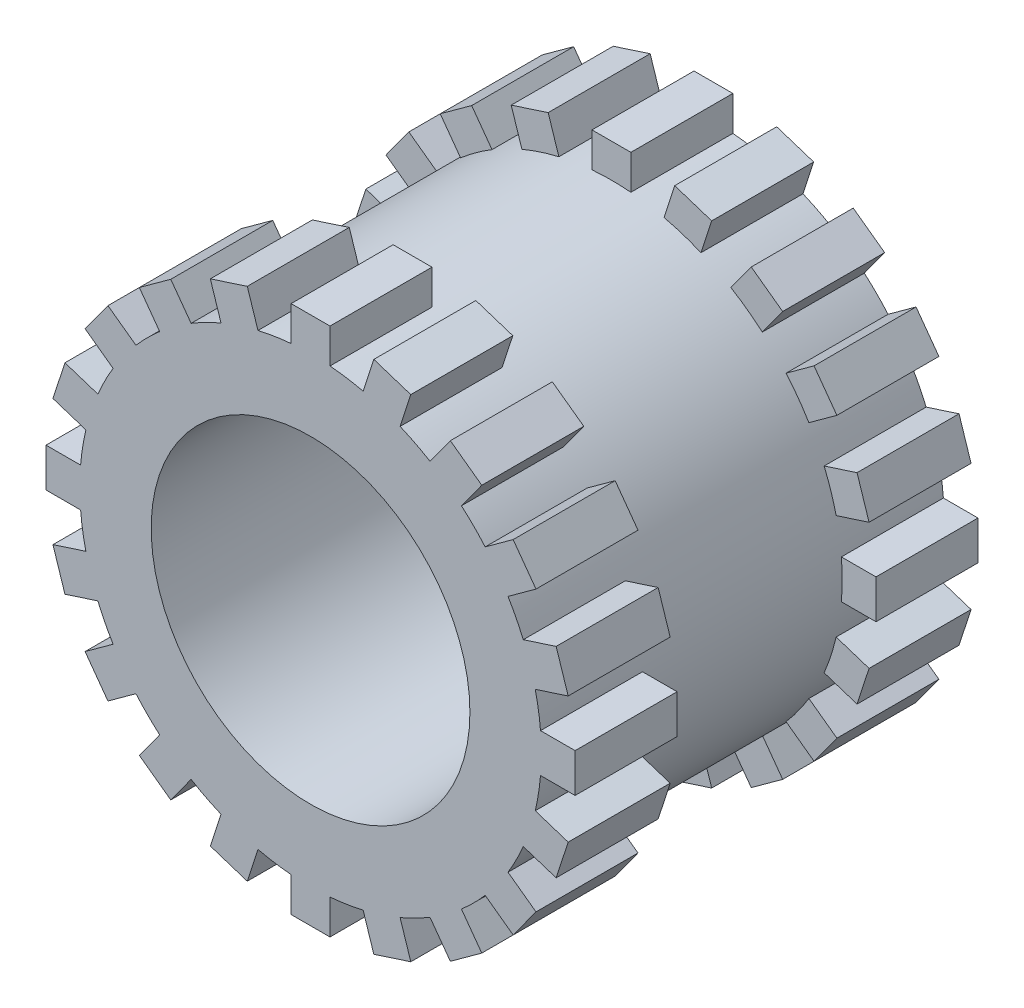
from build123d import *

# Parameters (mm, degrees)
SKETCH1_R                   = 1.81
BOSS_EXTRUDE1_DEPTH         = 1.58
TAP_DRILL_FOR_M3X0_5_TAP1_D = 2.5
SKETCH4_W                   = 0.3048
SKETCH4_H                   = 0.271427368
BOSS_EXTRUDE2_DEPTH         = 0.8
CIRPATTERN1_COUNT           = 20
MIRROR1_COPY_1_SKETCH_W     = 0.3048
MIRROR1_COPY_1_SKETCH_H     = 0.271427368
MIRROR1_COPY_1_DEPTH        = 0.8
MIRROR1_COPY_2_SKETCH_W     = 0.3048
MIRROR1_COPY_2_SKETCH_H     = 0.271427368
MIRROR1_COPY_2_DEPTH        = 0.8
MIRROR1_COPY_3_SKETCH_W     = 0.3048
MIRROR1_COPY_3_SKETCH_H     = 0.271427368
MIRROR1_COPY_3_DEPTH        = 0.8
MIRROR1_COPY_4_SKETCH_W     = 0.3048
MIRROR1_COPY_4_SKETCH_H     = 0.271427368
MIRROR1_COPY_4_DEPTH        = 0.8
MIRROR1_COPY_5_SKETCH_W     = 0.3048
MIRROR1_COPY_5_SKETCH_H     = 0.271427368
MIRROR1_COPY_5_DEPTH        = 0.8
MIRROR1_COPY_6_SKETCH_W     = 0.3048
MIRROR1_COPY_6_SKETCH_H     = 0.271427368
MIRROR1_COPY_6_DEPTH        = 0.8
MIRROR1_COPY_7_SKETCH_W     = 0.3048
MIRROR1_COPY_7_SKETCH_H     = 0.271427368
MIRROR1_COPY_7_DEPTH        = 0.8
MIRROR1_COPY_8_SKETCH_W     = 0.3048
MIRROR1_COPY_8_SKETCH_H     = 0.271427368
MIRROR1_COPY_8_DEPTH        = 0.8
MIRROR1_COPY_9_SKETCH_W     = 0.3048
MIRROR1_COPY_9_SKETCH_H     = 0.271427368
MIRROR1_COPY_9_DEPTH        = 0.8
MIRROR1_COPY_10_SKETCH_W    = 0.3048
MIRROR1_COPY_10_SKETCH_H    = 0.271427368
MIRROR1_COPY_10_DEPTH       = 0.8
MIRROR1_COPY_11_SKETCH_W    = 0.3048
MIRROR1_COPY_11_SKETCH_H    = 0.271427368
MIRROR1_COPY_11_DEPTH       = 0.8
MIRROR1_COPY_12_SKETCH_W    = 0.3048
MIRROR1_COPY_12_SKETCH_H    = 0.271427368
MIRROR1_COPY_12_DEPTH       = 0.8
MIRROR1_COPY_13_SKETCH_W    = 0.3048
MIRROR1_COPY_13_SKETCH_H    = 0.271427368
MIRROR1_COPY_13_DEPTH       = 0.8
MIRROR1_COPY_14_SKETCH_W    = 0.3048
MIRROR1_COPY_14_SKETCH_H    = 0.271427368
MIRROR1_COPY_14_DEPTH       = 0.8
MIRROR1_COPY_15_SKETCH_W    = 0.3048
MIRROR1_COPY_15_SKETCH_H    = 0.271427368
MIRROR1_COPY_15_DEPTH       = 0.8
MIRROR1_COPY_16_SKETCH_W    = 0.3048
MIRROR1_COPY_16_SKETCH_H    = 0.271427368
MIRROR1_COPY_16_DEPTH       = 0.8
MIRROR1_COPY_17_SKETCH_W    = 0.3048
MIRROR1_COPY_17_SKETCH_H    = 0.271427368
MIRROR1_COPY_17_DEPTH       = 0.8
MIRROR1_COPY_18_SKETCH_W    = 0.3048
MIRROR1_COPY_18_SKETCH_H    = 0.271427368
MIRROR1_COPY_18_DEPTH       = 0.8
MIRROR1_COPY_19_SKETCH_W    = 0.3048
MIRROR1_COPY_19_SKETCH_H    = 0.271427368
MIRROR1_COPY_19_DEPTH       = 0.8


with BuildPart() as part:
    # Sketch1 → Boss-Extrude1 (new body, symmetric)
    with BuildSketch(Plane.XY):
        Circle(SKETCH1_R)
    extrude(amount=BOSS_EXTRUDE1_DEPTH, both=True)

    # Tap Drill for M3x0.5 Tap1 (through all)
    with Locations(Plane.XY.offset(1.58)):
        with Locations((0, 0)):
            Hole(TAP_DRILL_FOR_M3X0_5_TAP1_D / 2)

    # Sketch4 → Boss-Extrude2 (add)
    with BuildSketch(Plane.XY.offset(1.58)):
        with Locations((0, 1.939286316)):
            Rectangle(SKETCH4_W, SKETCH4_H)
    boss_extrude2 = extrude(amount=-BOSS_EXTRUDE2_DEPTH)

    # CirPattern1: Boss-Extrude2 ×20 about axis
    cirpattern1_axis = Axis((0, 0, 0), (0, 0, 1))
    for i in range(1, CIRPATTERN1_COUNT):
        add(boss_extrude2.rotate(cirpattern1_axis, i * 360 / CIRPATTERN1_COUNT))

    # Mirror1: Boss-Extrude2 across plane
    add(boss_extrude2.mirror(Plane.XY))

    # Mirror1 copy 1 sketch → Mirror1 copy 1 (add)
    with BuildSketch(Plane(origin=(0, 0, -1.58), x_dir=(0.951056516, 0.309016994, 0), z_dir=(0, 0, -1))):
        with Locations((0, -1.939286316)):
            Rectangle(MIRROR1_COPY_1_SKETCH_W, MIRROR1_COPY_1_SKETCH_H)
    extrude(amount=-MIRROR1_COPY_1_DEPTH)

    # Mirror1 copy 2 sketch → Mirror1 copy 2 (add)
    with BuildSketch(Plane(origin=(0, 0, -1.58), x_dir=(0.809016994, 0.587785252, 0), z_dir=(0, 0, -1))):
        with Locations((0, -1.939286316)):
            Rectangle(MIRROR1_COPY_2_SKETCH_W, MIRROR1_COPY_2_SKETCH_H)
    extrude(amount=-MIRROR1_COPY_2_DEPTH)

    # Mirror1 copy 3 sketch → Mirror1 copy 3 (add)
    with BuildSketch(Plane(origin=(0, 0, -1.58), x_dir=(0.587785252, 0.809016994, 0), z_dir=(0, 0, -1))):
        with Locations((0, -1.939286316)):
            Rectangle(MIRROR1_COPY_3_SKETCH_W, MIRROR1_COPY_3_SKETCH_H)
    extrude(amount=-MIRROR1_COPY_3_DEPTH)

    # Mirror1 copy 4 sketch → Mirror1 copy 4 (add)
    with BuildSketch(Plane(origin=(0, 0, -1.58), x_dir=(0.309016994, 0.951056516, 0), z_dir=(0, 0, -1))):
        with Locations((0, -1.939286316)):
            Rectangle(MIRROR1_COPY_4_SKETCH_W, MIRROR1_COPY_4_SKETCH_H)
    extrude(amount=-MIRROR1_COPY_4_DEPTH)

    # Mirror1 copy 5 sketch → Mirror1 copy 5 (add)
    with BuildSketch(Plane.YX.offset(1.58)):
        with Locations((0, -1.939286316)):
            Rectangle(MIRROR1_COPY_5_SKETCH_W, MIRROR1_COPY_5_SKETCH_H)
    extrude(amount=-MIRROR1_COPY_5_DEPTH)

    # Mirror1 copy 6 sketch → Mirror1 copy 6 (add)
    with BuildSketch(Plane(origin=(0, 0, -1.58), x_dir=(-0.309016994, 0.951056516, 0), z_dir=(0, 0, -1))):
        with Locations((0, -1.939286316)):
            Rectangle(MIRROR1_COPY_6_SKETCH_W, MIRROR1_COPY_6_SKETCH_H)
    extrude(amount=-MIRROR1_COPY_6_DEPTH)

    # Mirror1 copy 7 sketch → Mirror1 copy 7 (add)
    with BuildSketch(Plane(origin=(0, 0, -1.58), x_dir=(-0.587785252, 0.809016994, 0), z_dir=(0, 0, -1))):
        with Locations((0, -1.939286316)):
            Rectangle(MIRROR1_COPY_7_SKETCH_W, MIRROR1_COPY_7_SKETCH_H)
    extrude(amount=-MIRROR1_COPY_7_DEPTH)

    # Mirror1 copy 8 sketch → Mirror1 copy 8 (add)
    with BuildSketch(Plane(origin=(0, 0, -1.58), x_dir=(-0.809016994, 0.587785252, 0), z_dir=(0, 0, -1))):
        with Locations((0, -1.939286316)):
            Rectangle(MIRROR1_COPY_8_SKETCH_W, MIRROR1_COPY_8_SKETCH_H)
    extrude(amount=-MIRROR1_COPY_8_DEPTH)

    # Mirror1 copy 9 sketch → Mirror1 copy 9 (add)
    with BuildSketch(Plane(origin=(0, 0, -1.58), x_dir=(-0.951056516, 0.309016994, 0), z_dir=(0, 0, -1))):
        with Locations((0, -1.939286316)):
            Rectangle(MIRROR1_COPY_9_SKETCH_W, MIRROR1_COPY_9_SKETCH_H)
    extrude(amount=-MIRROR1_COPY_9_DEPTH)

    # Mirror1 copy 10 sketch → Mirror1 copy 10 (add)
    with BuildSketch(Plane(origin=(0, 0, -1.58), x_dir=(-1, 0, 0), z_dir=(0, 0, -1))):
        with Locations((0, -1.939286316)):
            Rectangle(MIRROR1_COPY_10_SKETCH_W, MIRROR1_COPY_10_SKETCH_H)
    extrude(amount=-MIRROR1_COPY_10_DEPTH)

    # Mirror1 copy 11 sketch → Mirror1 copy 11 (add)
    with BuildSketch(Plane(origin=(0, 0, -1.58), x_dir=(-0.951056516, -0.309016994, 0), z_dir=(0, 0, -1))):
        with Locations((0, -1.939286316)):
            Rectangle(MIRROR1_COPY_11_SKETCH_W, MIRROR1_COPY_11_SKETCH_H)
    extrude(amount=-MIRROR1_COPY_11_DEPTH)

    # Mirror1 copy 12 sketch → Mirror1 copy 12 (add)
    with BuildSketch(Plane(origin=(0, 0, -1.58), x_dir=(-0.809016994, -0.587785252, 0), z_dir=(0, 0, -1))):
        with Locations((0, -1.939286316)):
            Rectangle(MIRROR1_COPY_12_SKETCH_W, MIRROR1_COPY_12_SKETCH_H)
    extrude(amount=-MIRROR1_COPY_12_DEPTH)

    # Mirror1 copy 13 sketch → Mirror1 copy 13 (add)
    with BuildSketch(Plane(origin=(0, 0, -1.58), x_dir=(-0.587785252, -0.809016994, 0), z_dir=(0, 0, -1))):
        with Locations((0, -1.939286316)):
            Rectangle(MIRROR1_COPY_13_SKETCH_W, MIRROR1_COPY_13_SKETCH_H)
    extrude(amount=-MIRROR1_COPY_13_DEPTH)

    # Mirror1 copy 14 sketch → Mirror1 copy 14 (add)
    with BuildSketch(Plane(origin=(0, 0, -1.58), x_dir=(-0.309016994, -0.951056516, 0), z_dir=(0, 0, -1))):
        with Locations((0, -1.939286316)):
            Rectangle(MIRROR1_COPY_14_SKETCH_W, MIRROR1_COPY_14_SKETCH_H)
    extrude(amount=-MIRROR1_COPY_14_DEPTH)

    # Mirror1 copy 15 sketch → Mirror1 copy 15 (add)
    with BuildSketch(Plane(origin=(0, 0, -1.58), x_dir=(0, -1, 0), z_dir=(0, 0, -1))):
        with Locations((0, -1.939286316)):
            Rectangle(MIRROR1_COPY_15_SKETCH_W, MIRROR1_COPY_15_SKETCH_H)
    extrude(amount=-MIRROR1_COPY_15_DEPTH)

    # Mirror1 copy 16 sketch → Mirror1 copy 16 (add)
    with BuildSketch(Plane(origin=(0, 0, -1.58), x_dir=(0.309016994, -0.951056516, 0), z_dir=(0, 0, -1))):
        with Locations((0, -1.939286316)):
            Rectangle(MIRROR1_COPY_16_SKETCH_W, MIRROR1_COPY_16_SKETCH_H)
    extrude(amount=-MIRROR1_COPY_16_DEPTH)

    # Mirror1 copy 17 sketch → Mirror1 copy 17 (add)
    with BuildSketch(Plane(origin=(0, 0, -1.58), x_dir=(0.587785252, -0.809016994, 0), z_dir=(0, 0, -1))):
        with Locations((0, -1.939286316)):
            Rectangle(MIRROR1_COPY_17_SKETCH_W, MIRROR1_COPY_17_SKETCH_H)
    extrude(amount=-MIRROR1_COPY_17_DEPTH)

    # Mirror1 copy 18 sketch → Mirror1 copy 18 (add)
    with BuildSketch(Plane(origin=(0, 0, -1.58), x_dir=(0.809016994, -0.587785252, 0), z_dir=(0, 0, -1))):
        with Locations((0, -1.939286316)):
            Rectangle(MIRROR1_COPY_18_SKETCH_W, MIRROR1_COPY_18_SKETCH_H)
    extrude(amount=-MIRROR1_COPY_18_DEPTH)

    # Mirror1 copy 19 sketch → Mirror1 copy 19 (add)
    with BuildSketch(Plane(origin=(0, 0, -1.58), x_dir=(0.951056516, -0.309016994, 0), z_dir=(0, 0, -1))):
        with Locations((0, -1.939286316)):
            Rectangle(MIRROR1_COPY_19_SKETCH_W, MIRROR1_COPY_19_SKETCH_H)
    extrude(amount=-MIRROR1_COPY_19_DEPTH)


solid = part.part
